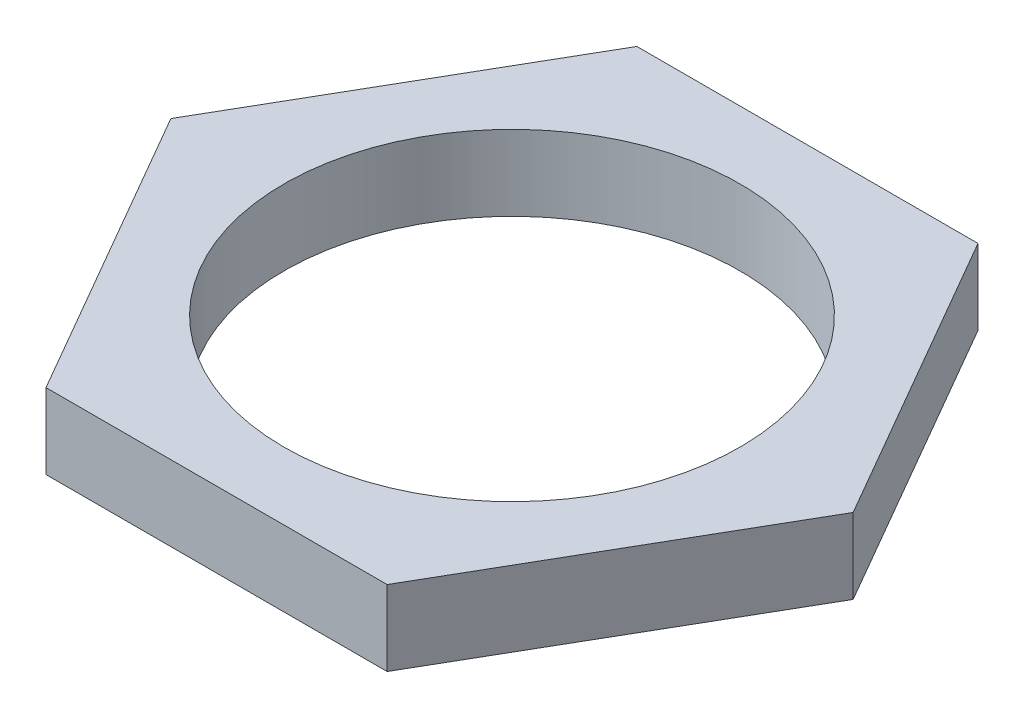
from build123d import *

# Parameters (mm, degrees)
SKETCH1_R           = 5.75
BOSS_EXTRUDE1_DEPTH = 1.9


with BuildPart() as part:
    # Sketch1 → Boss-Extrude1 (new body)
    with BuildSketch(Plane(origin=(0, 0, 0), x_dir=(1, 0, 0), z_dir=(0, 1, 0))):
        Polygon((-8.602519011, 0), (-4.301259505, -7.45), (4.301259505, -7.45), (8.602519011, 0), (4.301259505, 7.45), (-4.301259505, 7.45), align=None)
        Circle(SKETCH1_R, mode=Mode.SUBTRACT)
    extrude(amount=BOSS_EXTRUDE1_DEPTH)


solid = part.part
